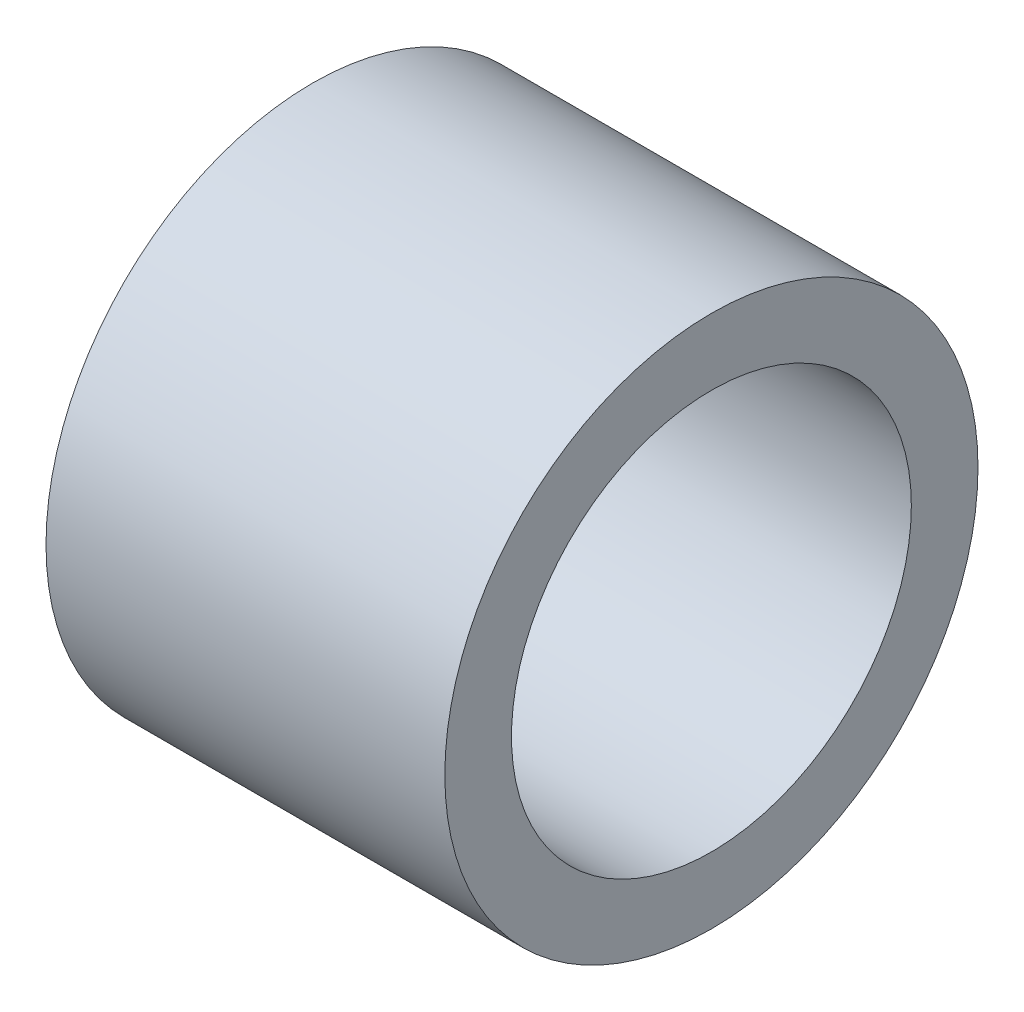
from build123d import *

# Parameters (mm, degrees)
SKETCH1_R           = 12.7
SKETCH1_R_2         = 9.525
BOSS_EXTRUDE1_DEPTH = 9.5


with BuildPart() as part:
    # Sketch1 → Boss-Extrude1 (new body, symmetric)
    with BuildSketch(Plane(origin=(0, 0, 0), x_dir=(0, 0, -1), z_dir=(1, 0, 0))):
        Circle(SKETCH1_R)
        Circle(SKETCH1_R_2, mode=Mode.SUBTRACT)
    extrude(amount=BOSS_EXTRUDE1_DEPTH, both=True)


solid = part.part
